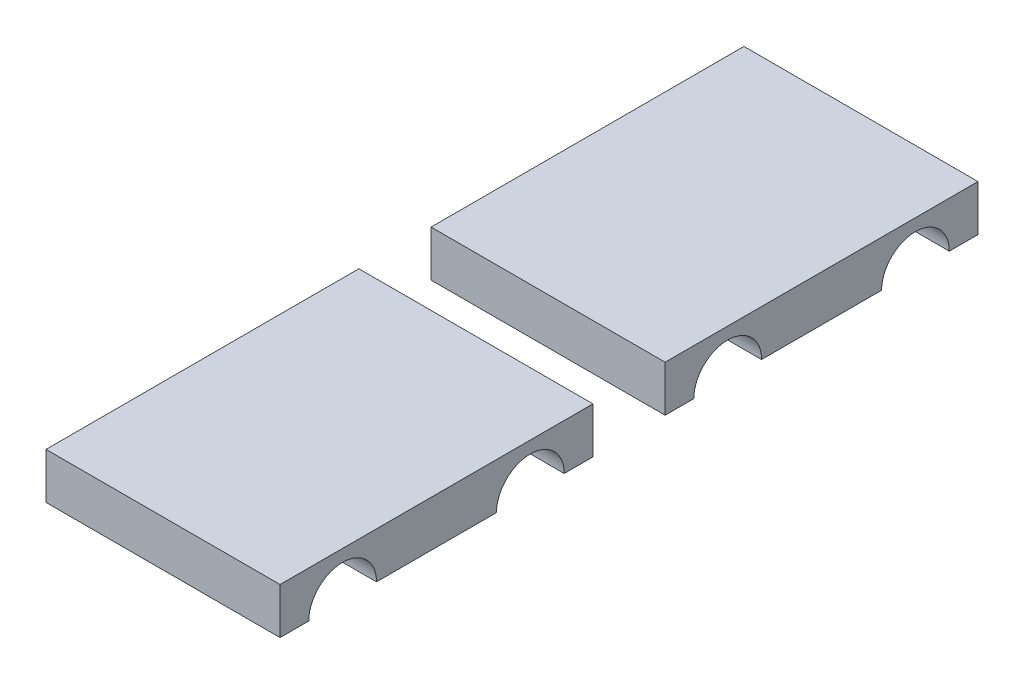
from build123d import *

# Parameters (mm, degrees)
REVOLVE1_ANGLE           = 180
BOSS_EXTRUDE1_DEPTH      = 9.25
BOSS_EXTRUDE1_DEPTH_BACK = 9.25
BOSS_EXTRUDE2_START      = 3.5
BOSS_EXTRUDE2_DEPTH      = 5.75
BOSS_EXTRUDE3_START      = -3.5
BOSS_EXTRUDE3_DEPTH      = 5.75
SKETCH13_W               = 5.5
SKETCH13_H               = 2.75
CUT_EXTRUDE9_DEPTH       = 1.75
SKETCH16_W               = 19
SKETCH16_H               = 4.169999961
CUT_EXTRUDE10_DEPTH      = 6
SKETCH17_W               = 19
SKETCH17_H               = 25.400000078
CUT_EXTRUDE13_DEPTH      = 1.27


with BuildPart() as part:
    # Sketch6 → Revolve1 (revolve)
    with BuildSketch(Plane(origin=(0, 0, 0), x_dir=(1, 0, 0), z_dir=(0, 1, 0))):
        Polygon((0, 5), (0, 2.75), (8, 2.75), (8, 2.25), (9, 2.75), (15, 2.75), (15, 2.25), (16, 2.75), (19, 2.75), (19, 5), align=None)
    revolve(axis=Axis((0, 0, 0), (1, 0, 0)), revolution_arc=REVOLVE1_ANGLE)

    # Sketch9 → Boss-Extrude1 (add, two sides)
    with BuildSketch(Plane.XY) as boss_extrude1_sk:
        Polygon((0, 3.25), (0, 5), (19, 5), (19, 2.75), align=None)
    extrude(amount=BOSS_EXTRUDE1_DEPTH)
    extrude(boss_extrude1_sk.sketch, amount=-BOSS_EXTRUDE1_DEPTH_BACK)

    # Sketch9_3 → Boss-Extrude2 (add)
    with BuildSketch(Plane.XY.offset(BOSS_EXTRUDE2_START)):
        Polygon((0, 3.25), (19, 2.75), (19, 0), (0, 0), align=None)
    extrude(amount=BOSS_EXTRUDE2_DEPTH)

    # Sketch9_4 → Boss-Extrude3 (add)
    with BuildSketch(Plane.XY.offset(BOSS_EXTRUDE3_START)):
        Polygon((0, 3.25), (19, 2.75), (19, 0), (0, 0), align=None)
    extrude(amount=-BOSS_EXTRUDE3_DEPTH)

    # Sketch13 → Cut-Extrude9 (cut)
    with BuildSketch(Plane.ZY):
        with Locations((0, 1.375)):
            Rectangle(SKETCH13_W, SKETCH13_H)
    extrude(amount=-CUT_EXTRUDE9_DEPTH, mode=Mode.SUBTRACT)

    # Mirror4: part across plane


with BuildPart() as part_1:
    add(part.part)
    add(part.part.mirror(Plane.XY.offset(-7.62)))

    # Sketch16 → Cut-Extrude10 (cut, through all)
    with BuildSketch(Plane(origin=(0, 5, 0), x_dir=(1, 0, 0), z_dir=(0, 1, 0))):
        with Locations((9.5, 22.40500002)):
            Rectangle(SKETCH16_W, SKETCH16_H)
        with Locations((9.5, -7.16500002)):
            Rectangle(SKETCH16_W, SKETCH16_H)
    extrude(amount=-CUT_EXTRUDE10_DEPTH, mode=Mode.SUBTRACT)

    # Sketch17 → Cut-Extrude13 (cut)
    with BuildSketch(Plane(origin=(0, 5, 0), x_dir=(1, 0, 0), z_dir=(0, 1, 0))):
        with Locations((9.5, 7.62)):
            Rectangle(SKETCH17_W, SKETCH17_H)
    extrude(amount=-CUT_EXTRUDE13_DEPTH, mode=Mode.SUBTRACT)


with BuildPart() as body_2:
    # Mirror1: mirrored copy
    add(part_1.part.mirror(Plane(origin=(0, 0, -23.25), x_dir=(1, 0, 0), z_dir=(0, 0, -1))))


solid = Compound([part_1.part, body_2.part])
